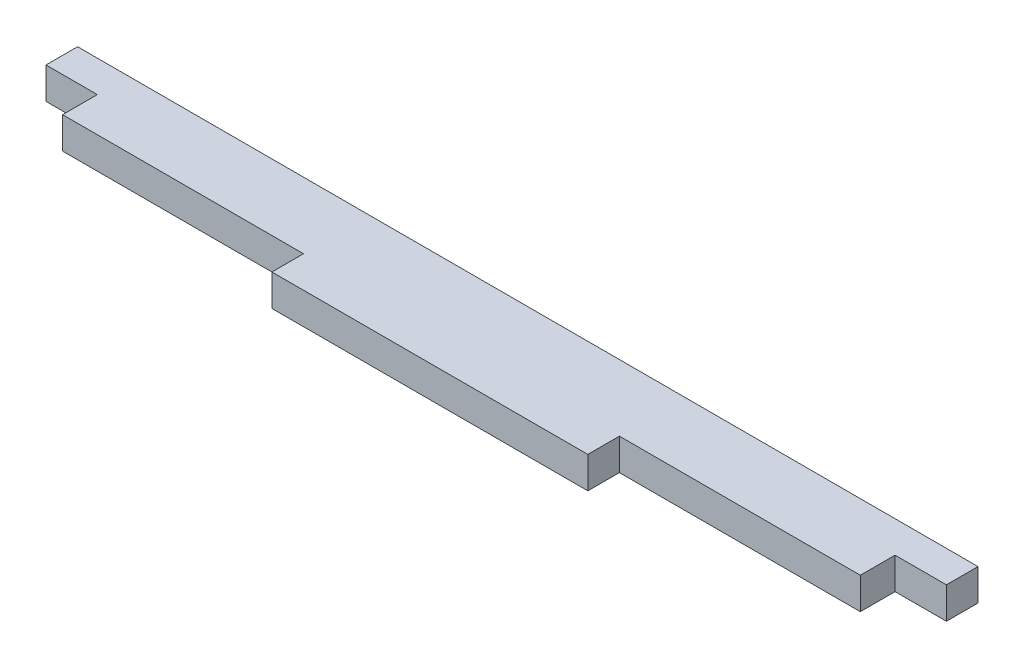
from build123d import *

# Parameters (mm, degrees)
BOSS_EXTRUDE1_DEPTH = 2


with BuildPart() as part:
    # Sketch1 → Boss-Extrude1 (new body)
    with BuildSketch(Plane(origin=(0, 0, 0), x_dir=(1, 0, 0), z_dir=(0, 1, 0))):
        Polygon((-25.25, 2), (-10, 2), (-10, 0), (10, 0), (10, 2), (25.25, 2), (25.25, 4.2), (28.5, 4.2), (28.5, 6.2), (-28.5, 6.2), (-28.5, 4.2), (-25.25, 4.2), align=None)
    extrude(amount=BOSS_EXTRUDE1_DEPTH)


solid = part.part
